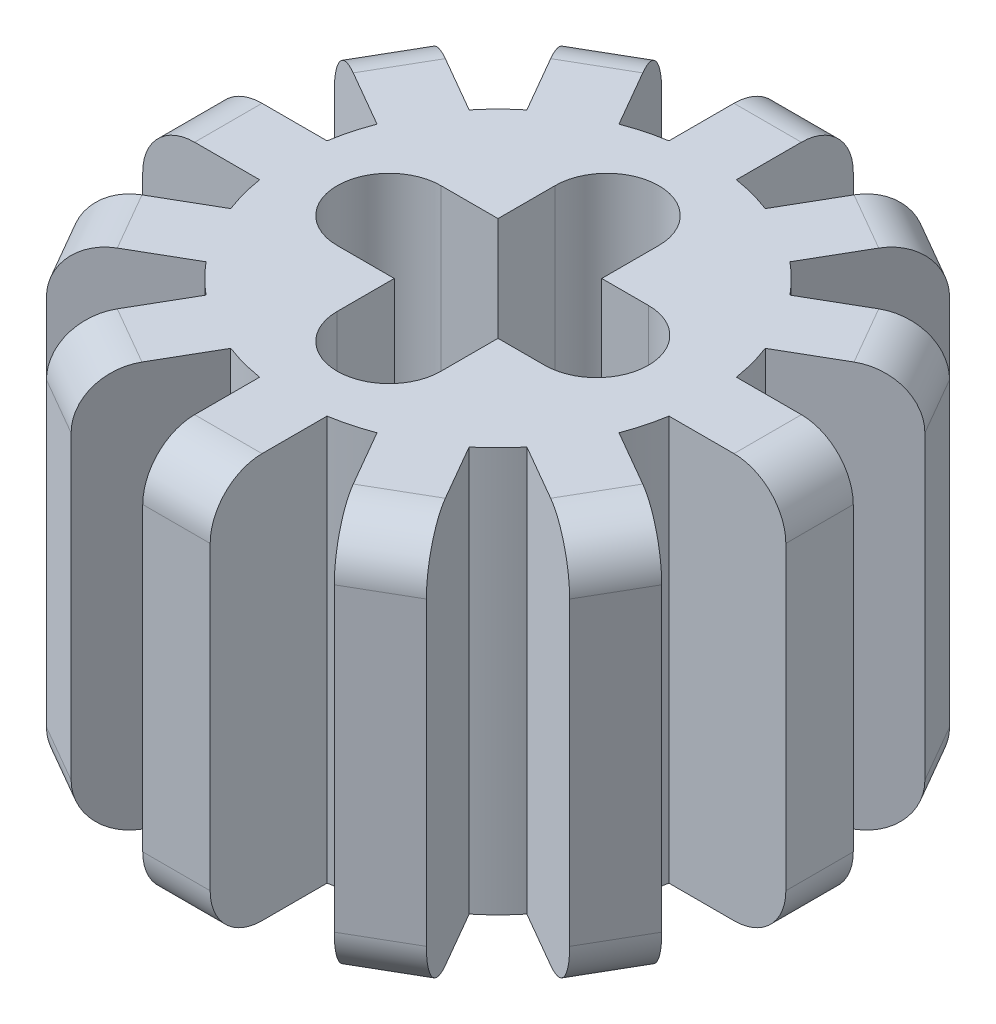
from build123d import *

# Parameters (mm, degrees)
SKETCH1_R           = 4
BOSS_EXTRUDE1_DEPTH = 3.9
BOSS_EXTRUDE2_DEPTH = 7.8
CIRPATTERN1_COUNT   = 12
SKETCH7_W           = 2
SKETCH7_H           = 2
CUT_EXTRUDE2_DEPTH  = 8.8
FILLET4_R           = 1
FILLET5_R           = 1
FILLET6_R           = 1
FILLET7_R           = 1
FILLET8_R           = 1
FILLET9_R           = 1
FILLET10_R          = 1
FILLET11_R          = 1
FILLET12_R          = 1
FILLET13_R          = 1
FILLET14_R          = 1
FILLET15_R          = 1
FILLET16_R          = 1
FILLET17_R          = 1
FILLET18_R          = 1
FILLET19_R          = 1
FILLET20_R          = 1
FILLET21_R          = 1
FILLET22_R          = 1
FILLET23_R          = 1
FILLET24_R          = 1
FILLET25_R          = 1
FILLET26_R          = 1
FILLET27_R          = 1


with BuildPart() as part:
    # Sketch1 → Boss-Extrude1 (new body, symmetric)
    with BuildSketch(Plane(origin=(0, 0, 0), x_dir=(1, 0, 0), z_dir=(0, 1, 0))):
        Circle(SKETCH1_R)
    extrude(amount=BOSS_EXTRUDE1_DEPTH, both=True)

    # Sketch5 → Boss-Extrude2 (add)
    with BuildSketch(Plane(origin=(0, 3.9, 0), x_dir=(1, 0, 0), z_dir=(0, 1, 0))):
        with BuildLine():
            ThreePointArc((-0.65, 3.946834174), (-0.326085344, 3.986686387), (0, 4))
            Line((0, 4), (0, 6.2))
            Line((0, 6.2), (-0.65, 6.2))
            Line((-0.65, 6.2), (-0.65, 3.946834174))
        make_face()
        with BuildLine():
            Line((0, 6.2), (0, 4))
            ThreePointArc((0, 4), (0.326085344, 3.986686387), (0.65, 3.946834174))
            Line((0.65, 3.946834174), (0.65, 6.2))
            Line((0.65, 6.2), (0, 6.2))
        make_face()
    boss_extrude2 = extrude(amount=-BOSS_EXTRUDE2_DEPTH)

    # CirPattern1: Boss-Extrude2 ×12 about axis
    cirpattern1_axis = Axis((0, 0, 0), (0, 1, 0))
    for i in range(1, CIRPATTERN1_COUNT):
        add(boss_extrude2.rotate(cirpattern1_axis, i * 360 / CIRPATTERN1_COUNT))

    # Sketch7 → Cut-Extrude2 (cut, through all)
    with BuildSketch(Plane(origin=(0, 3.9, 0), x_dir=(1, 0, 0), z_dir=(0, 1, 0))):
        with BuildLine():
            Line((1, 1), (1, 2.1))
            ThreePointArc((1, 2.1), (0, 3.1), (-1, 2.1))
            Line((-1, 2.1), (-1, 1))
            Line((-1, 1), (1, 1))
        make_face()
        Rectangle(SKETCH7_W, SKETCH7_H)
        with BuildLine():
            Line((1.9, 1), (1, 1))
            Line((1, 1), (1, -1))
            Line((1, -1), (1.9, -1))
            ThreePointArc((1.9, -1), (2.9, 0), (1.9, 1))
        make_face()
        with BuildLine():
            Line((1, -2.1), (1, -1))
            Line((1, -1), (-1, -1))
            Line((-1, -1), (-1, -2.1))
            ThreePointArc((-1, -2.1), (0, -3.1), (1, -2.1))
        make_face()
        with BuildLine():
            Line((-1, -1), (-1, 1))
            Line((-1, 1), (-2.1, 1))
            ThreePointArc((-2.1, 1), (-3.1, 0), (-2.1, -1))
            Line((-2.1, -1), (-1, -1))
        make_face()
    extrude(amount=-CUT_EXTRUDE2_DEPTH, mode=Mode.SUBTRACT)

    # Fillet4
    fillet4_edges = [part.edges().sort_by_distance(p)[0] for p in [
        (3.1, 3.9, -5.369357503),
    ]]
    fillet(fillet4_edges, radius=FILLET4_R)

    # Fillet5
    fillet5_edges = [part.edges().sort_by_distance(p)[0] for p in [
        (5.369357503, 3.9, 3.1),
    ]]
    fillet(fillet5_edges, radius=FILLET5_R)

    # Fillet6
    fillet6_edges = [part.edges().sort_by_distance(p)[0] for p in [
        (6.2, 3.9, 0),
    ]]
    fillet(fillet6_edges, radius=FILLET6_R)

    # Fillet7
    fillet7_edges = [part.edges().sort_by_distance(p)[0] for p in [
        (5.369357503, -3.9, -3.1),
    ]]
    fillet(fillet7_edges, radius=FILLET7_R)

    # Fillet8
    fillet8_edges = [part.edges().sort_by_distance(p)[0] for p in [
        (3.1, -3.9, 5.369357503),
    ]]
    fillet(fillet8_edges, radius=FILLET8_R)

    # Fillet9
    fillet9_edges = [part.edges().sort_by_distance(p)[0] for p in [
        (3.1, 3.9, 5.369357503),
    ]]
    fillet(fillet9_edges, radius=FILLET9_R)

    # Fillet10
    fillet10_edges = [part.edges().sort_by_distance(p)[0] for p in [
        (0, 3.9, 6.2),
    ]]
    fillet(fillet10_edges, radius=FILLET10_R)

    # Fillet11
    fillet11_edges = [part.edges().sort_by_distance(p)[0] for p in [
        (-3.1, 3.9, 5.369357503),
    ]]
    fillet(fillet11_edges, radius=FILLET11_R)

    # Fillet12
    fillet12_edges = [part.edges().sort_by_distance(p)[0] for p in [
        (-5.369357503, 3.9, 3.1),
    ]]
    fillet(fillet12_edges, radius=FILLET12_R)

    # Fillet13
    fillet13_edges = [part.edges().sort_by_distance(p)[0] for p in [
        (-6.2, 3.9, 0),
    ]]
    fillet(fillet13_edges, radius=FILLET13_R)

    # Fillet14
    fillet14_edges = [part.edges().sort_by_distance(p)[0] for p in [
        (-3.1, 3.9, -5.369357503),
    ]]
    fillet(fillet14_edges, radius=FILLET14_R)

    # Fillet15
    fillet15_edges = [part.edges().sort_by_distance(p)[0] for p in [
        (-5.369357503, 3.9, -3.1),
    ]]
    fillet(fillet15_edges, radius=FILLET15_R)

    # Fillet16
    fillet16_edges = [part.edges().sort_by_distance(p)[0] for p in [
        (0, 3.9, -6.2),
    ]]
    fillet(fillet16_edges, radius=FILLET16_R)

    # Fillet17
    fillet17_edges = [part.edges().sort_by_distance(p)[0] for p in [
        (5.369357503, 3.9, -3.1),
    ]]
    fillet(fillet17_edges, radius=FILLET17_R)

    # Fillet18
    fillet18_edges = [part.edges().sort_by_distance(p)[0] for p in [
        (-6.2, -3.9, 0),
    ]]
    fillet(fillet18_edges, radius=FILLET18_R)

    # Fillet19
    fillet19_edges = [part.edges().sort_by_distance(p)[0] for p in [
        (-5.369357503, -3.9, 3.1),
    ]]
    fillet(fillet19_edges, radius=FILLET19_R)

    # Fillet20
    fillet20_edges = [part.edges().sort_by_distance(p)[0] for p in [
        (-3.1, -3.9, 5.369357503),
    ]]
    fillet(fillet20_edges, radius=FILLET20_R)

    # Fillet21
    fillet21_edges = [part.edges().sort_by_distance(p)[0] for p in [
        (0, -3.9, 6.2),
    ]]
    fillet(fillet21_edges, radius=FILLET21_R)

    # Fillet22
    fillet22_edges = [part.edges().sort_by_distance(p)[0] for p in [
        (5.369357503, -3.9, 3.1),
    ]]
    fillet(fillet22_edges, radius=FILLET22_R)

    # Fillet23
    fillet23_edges = [part.edges().sort_by_distance(p)[0] for p in [
        (6.2, -3.9, 0),
    ]]
    fillet(fillet23_edges, radius=FILLET23_R)

    # Fillet24
    fillet24_edges = [part.edges().sort_by_distance(p)[0] for p in [
        (0, -3.9, -6.2),
    ]]
    fillet(fillet24_edges, radius=FILLET24_R)

    # Fillet25
    fillet25_edges = [part.edges().sort_by_distance(p)[0] for p in [
        (-3.1, -3.9, -5.369357503),
    ]]
    fillet(fillet25_edges, radius=FILLET25_R)

    # Fillet26
    fillet26_edges = [part.edges().sort_by_distance(p)[0] for p in [
        (3.1, -3.9, -5.369357503),
    ]]
    fillet(fillet26_edges, radius=FILLET26_R)

    # Fillet27
    fillet27_edges = [part.edges().sort_by_distance(p)[0] for p in [
        (-5.369357503, -3.9, -3.1),
    ]]
    fillet(fillet27_edges, radius=FILLET27_R)


solid = part.part
